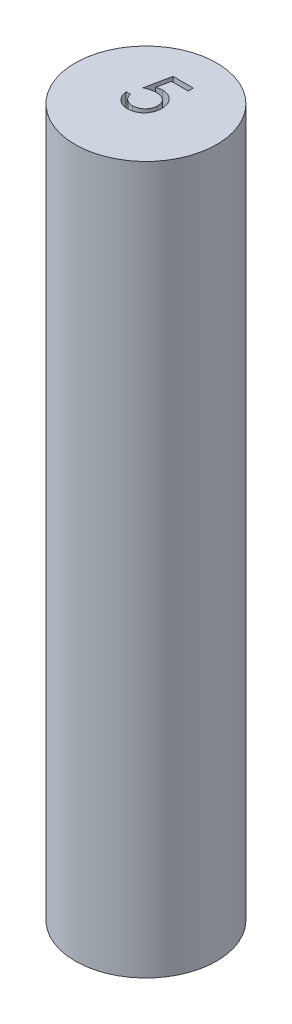
from build123d import *

# Parameters (mm, degrees)
SKETCH1_R           = 5
BOSS_EXTRUDE1_DEPTH = 50
CUT_EXTRUDE1_DEPTH  = 3


with BuildPart() as part:
    # Sketch1 → Boss-Extrude1 (new body)
    with BuildSketch(Plane(origin=(0, 0, 0), x_dir=(1, 0, 0), z_dir=(0, 1, 0))):
        Circle(SKETCH1_R)
    extrude(amount=BOSS_EXTRUDE1_DEPTH)

    # Sketch2 → Cut-Extrude1 (cut)
    with BuildSketch(Plane(origin=(0, 50, 0), x_dir=(1, 0, 0), z_dir=(0, 1, 0))):
        with BuildLine():
            Line((0.718635203, 2.631935528), (0.718635203, 2.272961169))
            Line((0.718635203, 2.272961169), (-0.471869605, 2.272961169))
            Line((-0.471869605, 2.272961169), (-0.660471368, 1.352388253))
            add(Edge.make_bspline(
                [(-0.660471368, 1.352388253), (-0.623415494, 1.362618525), (-0.551625598, 1.382438058), (-0.445665737, 1.404443829), (-0.345073533, 1.417709273), (-0.279798163, 1.419520583), (-0.248211753, 1.420397067)],
                knots=[0, 0, 0, 0, 0.000115302, 0.000223379, 0.000324431, 0.000419176, 0.000419176, 0.000419176, 0.000419176], degree=3))
            add(Edge.make_bspline(
                [(-0.248211753, 1.420397067), (-0.209128013, 1.419551131), (-0.132279616, 1.41788781), (-0.019840669, 1.401915961), (0.087492225, 1.376776046), (0.189494595, 1.341655524), (0.286355146, 1.296745791), (0.377182707, 1.240645851), (0.46334062, 1.17511252), (0.543283214, 1.099767508), (0.615807522, 1.016845891), (0.679573512, 0.92768802), (0.733736102, 0.833160358), (0.777296857, 0.732359749), (0.812081191, 0.626400596), (0.835233186, 0.514168013), (0.850649895, 0.396719893), (0.852372281, 0.316415323), (0.853250587, 0.275465176)],
                knots=[0, 0, 0, 0, 0.00011719, 0.000230425, 0.000339944, 0.000447481, 0.000553499, 0.000659556, 0.000767111, 0.000877722, 0.000988528, 0.001097091, 0.001206056, 0.001314692, 0.001425996, 0.001539995, 0.001658004, 0.001780798, 0.001780798, 0.001780798, 0.001780798], degree=3))
            add(Edge.make_bspline(
                [(0.853250587, 0.275465176), (0.852585512, 0.246942956), (0.851264349, 0.190283968), (0.844545762, 0.106139767), (0.831610046, 0.023776934), (0.814242321, -0.056815458), (0.791699904, -0.13548483), (0.76441085, -0.212456358), (0.731014822, -0.287250965), (0.694383447, -0.36057636), (0.653136969, -0.430774867), (0.607358461, -0.496423853), (0.55899297, -0.558508135), (0.506951585, -0.616361868), (0.45075059, -0.669604886), (0.391070623, -0.718553167), (0.328387904, -0.764034497), (0.261732661, -0.804202693), (0.192590179, -0.841165649), (0.119961961, -0.871489186), (0.045501261, -0.898599714), (-0.031863615, -0.920209242), (-0.111957427, -0.937141796), (-0.194912203, -0.948642397), (-0.280292873, -0.957018834), (-0.338167885, -0.957543191), (-0.367402458, -0.957808061)],
                knots=[0, 0, 0, 0, 8.5583e-05, 0.000170009, 0.000253005, 0.000335518, 0.000417186, 0.000498352, 0.000580291, 0.000662755, 0.000744161, 0.000824288, 0.000902692, 0.000980133, 0.001057498, 0.001134702, 0.00121156, 0.001289599, 0.001368002, 0.001446531, 0.001525481, 0.001605609, 0.001687289, 0.001770875, 0.001856759, 0.001944425, 0.001944425, 0.001944425, 0.001944425], degree=3))
            add(Edge.make_bspline(
                [(-0.367402458, -0.957808061), (-0.402276638, -0.957117223), (-0.470887469, -0.955758081), (-0.571408036, -0.941539596), (-0.668122642, -0.92117568), (-0.760252743, -0.89053941), (-0.848624007, -0.852152115), (-0.932046724, -0.803635944), (-1.012652501, -0.74865684), (-1.087164537, -0.683776487), (-1.156320651, -0.612860805), (-1.21822716, -0.535903164), (-1.273360736, -0.454173722), (-1.320838483, -0.367275567), (-1.361336505, -0.275437037), (-1.393151493, -0.178314036), (-1.418829848, -0.076414032), (-1.429693268, -0.006260521), (-1.435210951, 0.029371426)],
                knots=[0, 0, 0, 0, 0.000104552, 0.000205693, 0.000304023, 0.000400691, 0.00049644, 0.000592535, 0.000689779, 0.000788716, 0.000888377, 0.000986596, 0.001084603, 0.001183757, 0.001283279, 0.001385267, 0.001490017, 0.001598135, 0.001598135, 0.001598135, 0.001598135], degree=3))
            Line((-1.435210951, 0.029371426), (-1.121108387, 0.029371426))
            add(Edge.make_bspline(
                [(-1.121108387, 0.029371426), (-1.11337983, -0.004005027), (-1.098525113, -0.068156421), (-1.065919365, -0.158287763), (-1.026053489, -0.238606986), (-0.978649141, -0.31017657), (-0.92209911, -0.372585567), (-0.857569681, -0.428202629), (-0.785221958, -0.478377758), (-0.704828729, -0.520200525), (-0.620015649, -0.555869279), (-0.531248439, -0.579620974), (-0.440944093, -0.596321867), (-0.379865723, -0.597993627), (-0.349173291, -0.598833702)],
                knots=[0, 0, 0, 0, 0.000102709, 0.000197412, 0.000286774, 0.000371169, 0.000454082, 0.000538572, 0.000626283, 0.000717552, 0.000809994, 0.00090168, 0.00099274, 0.001084718, 0.001084718, 0.001084718, 0.001084718], degree=3))
            add(Edge.make_bspline(
                [(-0.349173291, -0.598833702), (-0.319214847, -0.598012924), (-0.260226424, -0.596396806), (-0.173415038, -0.583957794), (-0.089602164, -0.564800223), (-0.009614807, -0.536130368), (0.067946733, -0.501285649), (0.141120503, -0.456570573), (0.21202338, -0.405110555), (0.278451514, -0.346153925), (0.339290963, -0.28118423), (0.393047084, -0.211706837), (0.437823998, -0.13758999), (0.475558107, -0.060116837), (0.504211405, 0.02156172), (0.524652387, 0.107062895), (0.536655445, 0.196597875), (0.538306625, 0.257667185), (0.539148023, 0.28878649)],
                knots=[0, 0, 0, 0, 8.9842e-05, 0.0001769, 0.000262612, 0.000347317, 0.000431396, 0.000517249, 0.000604055, 0.000693954, 0.000783242, 0.000870748, 0.000956963, 0.001042571, 0.001128832, 0.00121607, 0.001305907, 0.001399251, 0.001399251, 0.001399251, 0.001399251], degree=3))
            add(Edge.make_bspline(
                [(0.539148023, 0.28878649), (0.538489544, 0.316862242), (0.537200664, 0.371816531), (0.526670093, 0.452215737), (0.508353121, 0.528288779), (0.482929241, 0.600403013), (0.450649733, 0.668626456), (0.411203421, 0.733029516), (0.363850023, 0.792763349), (0.309758135, 0.847855903), (0.250500094, 0.898700778), (0.185056351, 0.942044864), (0.114796424, 0.978508782), (0.040566825, 1.00997678), (-0.039398074, 1.032577525), (-0.123514706, 1.049545411), (-0.212691414, 1.059360774), (-0.273662102, 1.060722662), (-0.305002618, 1.061422708)],
                knots=[0, 0, 0, 0, 8.4208e-05, 0.000164824, 0.000242709, 0.000318547, 0.000393815, 0.000468731, 0.000544614, 0.00062196, 0.000700062, 0.000778428, 0.000856831, 0.000937299, 0.001019835, 0.001105635, 0.00119452, 0.001288536, 0.001288536, 0.001288536, 0.001288536], degree=3))
            add(Edge.make_bspline(
                [(-0.305002618, 1.061422708), (-0.332131547, 1.060842117), (-0.388145902, 1.059643343), (-0.474068729, 1.050816846), (-0.564360452, 1.036577552), (-0.658674947, 1.016991305), (-0.757295455, 0.991360228), (-0.860013856, 0.960645727), (-0.967046123, 0.923923728), (-1.039163847, 0.896191515), (-1.076236592, 0.881935528)],
                knots=[0, 0, 0, 0, 8.1378e-05, 0.000168026, 0.000258858, 0.000355524, 0.000456875, 0.000564457, 0.000677092, 0.000796243, 0.000796243, 0.000796243, 0.000796243], degree=3))
            Line((-1.076236592, 0.881935528), (-0.717262233, 2.631935528))
            Line((-0.717262233, 2.631935528), (0.718635203, 2.631935528))
        make_face()
    extrude(amount=-CUT_EXTRUDE1_DEPTH, mode=Mode.SUBTRACT)


solid = part.part
